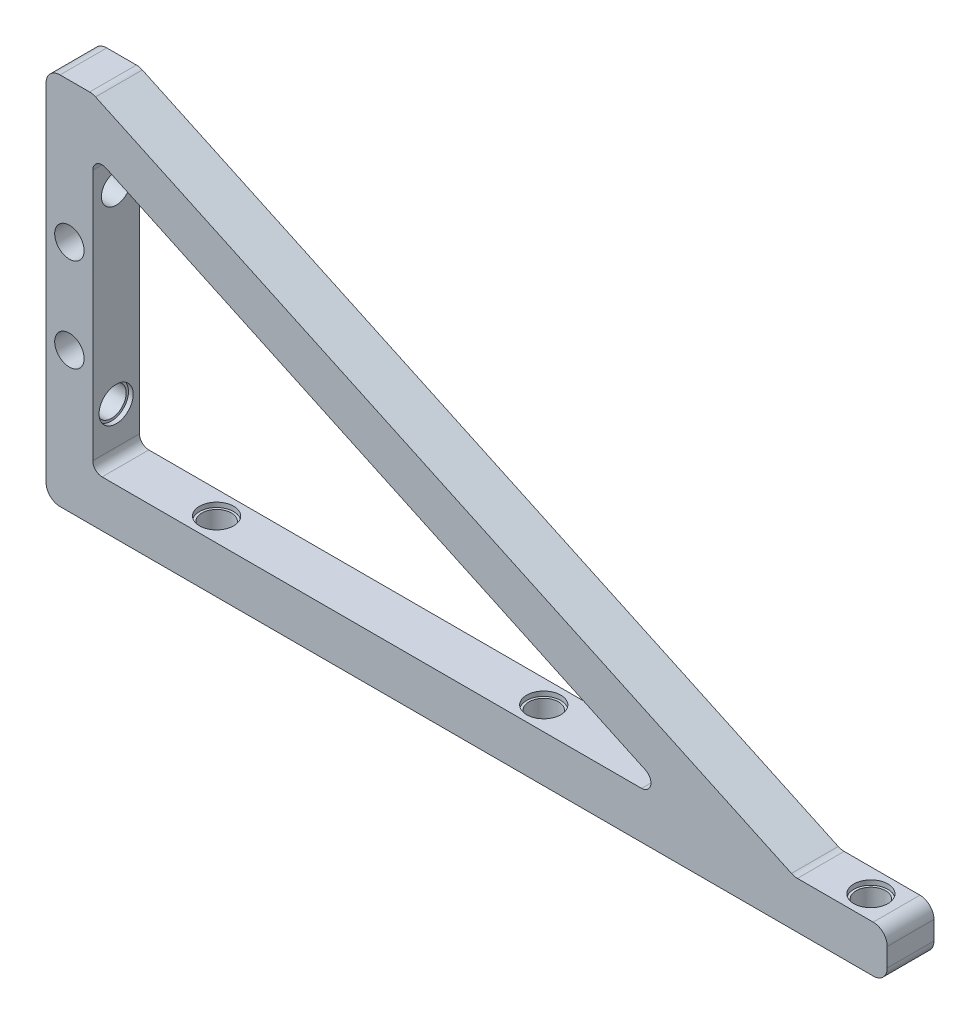
from build123d import *

# Parameters (mm, degrees)
ESQUISSE1_W                         = 180
ESQUISSE1_H                         = 80
BOSS_EXTRU_1_DEPTH                  = 10
ESQUISSE2_W                         = 170
ESQUISSE2_H                         = 70
ENL_V_MAT_EXTRU_1_DEPTH             = 1
ENL_V_MAT_EXTRU_1_DEPTH_BACK        = 11
BOSS_EXTRU_2_DEPTH                  = 10
ENL_V_MAT_EXTRU_2_REACH             = 82
ESQUISSE4_R                         = 3.15
ENL_V_MAT_EXTRU_2_DIRECTION_2_DEPTH = 1
ESQUISSE5_R                         = 3.65
ENL_V_MAT_EXTRU_3_DEPTH             = 1
ENL_V_MAT_EXTRU_4_REACH             = 182
ESQUISSE6_R                         = 3.15
ENL_V_MAT_EXTRU_4_DIRECTION_2_DEPTH = 1
ESQUISSE7_R                         = 3.65
ENL_V_MAT_EXTRU_5_DEPTH             = 1
ESQUISSE8_R                         = 3.65
ENL_V_MAT_EXTRU_6_DEPTH             = 1
CONG_1_R                            = 2
CONG_2_R                            = 3
ESQUISSE9_R                         = 3.15
ENL_V_MAT_EXTRU_7_DEPTH             = 1
ENL_V_MAT_EXTRU_7_DEPTH_BACK        = 11
ENL_V_START                         = -10
ESQUISSE10_R                        = 3.65
ENL_V_MAT_EXTRU_8_DEPTH             = 1


with BuildPart() as part:
    # Esquisse1 → Boss.-Extru.1 (new body)
    with BuildSketch(Plane.XY):
        with Locations((90, 40)):
            Rectangle(ESQUISSE1_W, ESQUISSE1_H)
    extrude(amount=BOSS_EXTRU_1_DEPTH)

    # Esquisse2 → Enlèv. mat.-Extru.1 (cut, two sides)
    with BuildSketch(Plane.XY.offset(10)) as enl_v_mat_extru_1_sk:
        with Locations((95, 45)):
            Rectangle(ESQUISSE2_W, ESQUISSE2_H)
    extrude(amount=ENL_V_MAT_EXTRU_1_DEPTH, mode=Mode.SUBTRACT)
    extrude(enl_v_mat_extru_1_sk.sketch, amount=-ENL_V_MAT_EXTRU_1_DEPTH_BACK, mode=Mode.SUBTRACT)

    # Esquisse3 → Boss.-Extru.2 (add)
    with BuildSketch(Plane.XY.offset(10)):
        Polygon((10, 80), (160.115484436, 10), (136.453468604, 10), (10, 68.96622081), align=None)
    extrude(amount=-BOSS_EXTRU_2_DEPTH)

    # Esquisse4 → Enlèv. mat.-Extru.2 (cut, up to next)
    with BuildSketch(Plane.XZ, mode=Mode.PRIVATE) as enl_v_mat_extru_2_sk1:
        with Locations((101.5, 5)):
            Circle(ESQUISSE4_R)
    enl_v_mat_extru_2_tool1 = extrude(enl_v_mat_extru_2_sk1.sketch, amount=-ENL_V_MAT_EXTRU_2_REACH, mode=Mode.PRIVATE) & part.part
    add(enl_v_mat_extru_2_tool1.solids().sort_by_distance((101.5, 0, 5))[0], mode=Mode.SUBTRACT)
    # Esquisse4 → Enlèv. mat.-Extru.2 (cut, up to next)
    with BuildSketch(Plane.XZ, mode=Mode.PRIVATE) as enl_v_mat_extru_2_sk2:
        with Locations((171.5, 5)):
            Circle(ESQUISSE4_R)
    enl_v_mat_extru_2_tool2 = extrude(enl_v_mat_extru_2_sk2.sketch, amount=-ENL_V_MAT_EXTRU_2_REACH, mode=Mode.PRIVATE) & part.part
    add(enl_v_mat_extru_2_tool2.solids().sort_by_distance((171.5, 0, 5))[0], mode=Mode.SUBTRACT)
    # Esquisse4 → Enlèv. mat.-Extru.2 (cut, up to next)
    with BuildSketch(Plane.XZ, mode=Mode.PRIVATE) as enl_v_mat_extru_2_sk3:
        with Locations((31.5, 5)):
            Circle(ESQUISSE4_R)
    enl_v_mat_extru_2_tool3 = extrude(enl_v_mat_extru_2_sk3.sketch, amount=-ENL_V_MAT_EXTRU_2_REACH, mode=Mode.PRIVATE) & part.part
    add(enl_v_mat_extru_2_tool3.solids().sort_by_distance((31.5, 0, 5))[0], mode=Mode.SUBTRACT)

    # Esquisse4 → Enlèv. mat.-Extru.2 direction 2 (cut)
    with BuildSketch(Plane.XZ):
        with Locations((101.5, 5)):
            Circle(ESQUISSE4_R)
        with Locations((171.5, 5)):
            Circle(ESQUISSE4_R)
        with Locations((31.5, 5)):
            Circle(ESQUISSE4_R)
    extrude(amount=ENL_V_MAT_EXTRU_2_DIRECTION_2_DEPTH, mode=Mode.SUBTRACT)

    # Esquisse5 → Enlèv. mat.-Extru.3 (cut)
    with BuildSketch(Plane(origin=(0, 10, 0), x_dir=(1, 0, 0), z_dir=(0, 1, 0))):
        with Locations((101.5, -5)):
            Circle(ESQUISSE5_R)
        with Locations((171.5, -5)):
            Circle(ESQUISSE5_R)
        with Locations((31.5, -5)):
            Circle(ESQUISSE5_R)
    extrude(amount=-ENL_V_MAT_EXTRU_3_DEPTH, mode=Mode.SUBTRACT)

    # Esquisse6 → Enlèv. mat.-Extru.4 (cut, up to next)
    with BuildSketch(Plane.ZY, mode=Mode.PRIVATE) as enl_v_mat_extru_4_sk1:
        with Locations((5, 60)):
            Circle(ESQUISSE6_R)
    enl_v_mat_extru_4_tool1 = extrude(enl_v_mat_extru_4_sk1.sketch, amount=-ENL_V_MAT_EXTRU_4_REACH, mode=Mode.PRIVATE) & part.part
    add(enl_v_mat_extru_4_tool1.solids().sort_by_distance((0, 60, 5))[0], mode=Mode.SUBTRACT)
    # Esquisse6 → Enlèv. mat.-Extru.4 (cut, up to next)
    with BuildSketch(Plane.ZY, mode=Mode.PRIVATE) as enl_v_mat_extru_4_sk2:
        with Locations((5, 20)):
            Circle(ESQUISSE6_R)
    enl_v_mat_extru_4_tool2 = extrude(enl_v_mat_extru_4_sk2.sketch, amount=-ENL_V_MAT_EXTRU_4_REACH, mode=Mode.PRIVATE) & part.part
    add(enl_v_mat_extru_4_tool2.solids().sort_by_distance((0, 20, 5))[0], mode=Mode.SUBTRACT)

    # Esquisse6 → Enlèv. mat.-Extru.4 direction 2 (cut)
    with BuildSketch(Plane.ZY):
        with Locations((5, 60)):
            Circle(ESQUISSE6_R)
        with Locations((5, 20)):
            Circle(ESQUISSE6_R)
    extrude(amount=ENL_V_MAT_EXTRU_4_DIRECTION_2_DEPTH, mode=Mode.SUBTRACT)

    # Esquisse7 → Enlèv. mat.-Extru.5 (cut)
    with BuildSketch(Plane.ZY):
        with Locations((5, 60)):
            Circle(ESQUISSE7_R)
    extrude(amount=-ENL_V_MAT_EXTRU_5_DEPTH, mode=Mode.SUBTRACT)

    # Esquisse8 → Enlèv. mat.-Extru.6 (cut)
    with BuildSketch(Plane(origin=(10, 0, 0), x_dir=(0, 0, -1), z_dir=(1, 0, 0))):
        with Locations((-5, 20)):
            Circle(ESQUISSE8_R)
    extrude(amount=-ENL_V_MAT_EXTRU_6_DEPTH, mode=Mode.SUBTRACT)

    # Congé1
    cong_1_edges = [part.edges().sort_by_distance(p)[0] for p in [
        (10, 10, 5),
        (10, 68.96622081, 5),
        (136.453468604, 10, 5),
    ]]
    fillet(cong_1_edges, radius=CONG_1_R)

    # Congé2
    cong_2_edges = [part.edges().sort_by_distance(p)[0] for p in [
        (10, 80, 5),
        (180, 10, 5),
        (160.115484436, 10, 5),
        (0, 80, 5),
        (180, 0, 5),
        (0, 0, 5),
    ]]
    fillet(cong_2_edges, radius=CONG_2_R)

    # Esquisse9 → Enlèv. mat.-Extru.7 (cut, two sides)
    with BuildSketch(Plane.XY.offset(10)) as enl_v_mat_extru_7_sk:
        with Locations((5, 50)):
            Circle(ESQUISSE9_R)
        with Locations((5, 30)):
            Circle(ESQUISSE9_R)
    extrude(amount=ENL_V_MAT_EXTRU_7_DEPTH, mode=Mode.SUBTRACT)
    extrude(enl_v_mat_extru_7_sk.sketch, amount=-ENL_V_MAT_EXTRU_7_DEPTH_BACK, mode=Mode.SUBTRACT)

    # Esquisse10 → Enlèv. mat.-Extru.8 (cut)
    with BuildSketch(Plane.XY.offset(10).offset(ENL_V_START)):
        with Locations((5, 50)):
            Circle(ESQUISSE10_R)
        with Locations((5, 30)):
            Circle(ESQUISSE10_R)
    extrude(amount=ENL_V_MAT_EXTRU_8_DEPTH, mode=Mode.SUBTRACT)


solid = part.part
